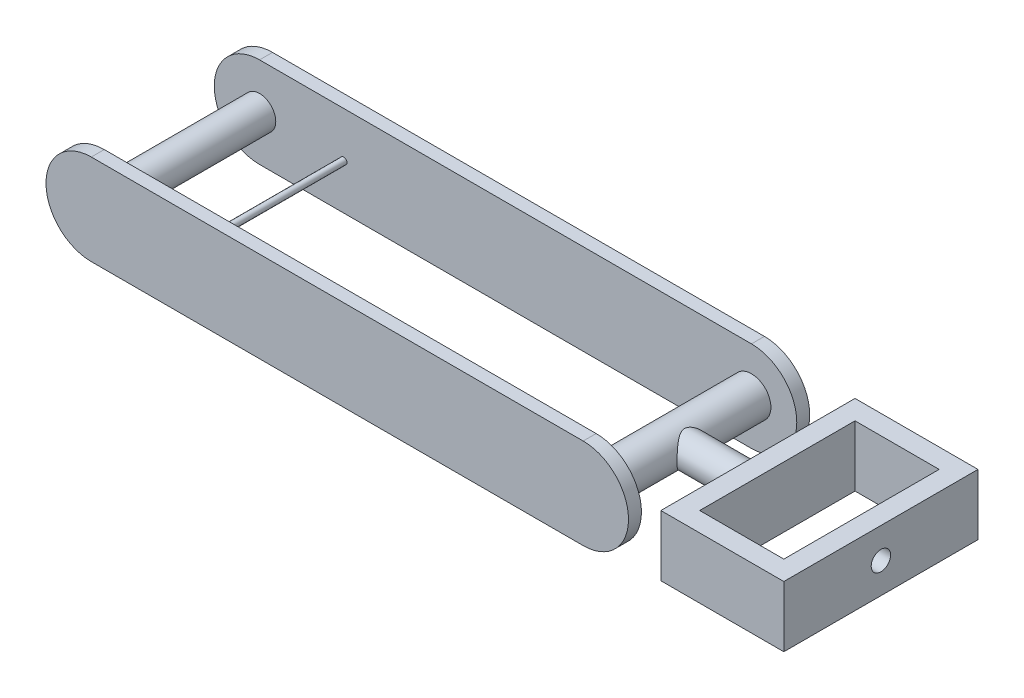
from build123d import *

# Parameters (mm, degrees)
BOSS_EXTRUDE1_DEPTH = 10
BOSS_EXTRUDE2_DEPTH = 10
SKETCH3_R           = 12.5
BOSS_EXTRUDE3_DEPTH = 145
SKETCH4_R           = 2.5
BOSS_EXTRUDE4_DEPTH = 145
SKETCH5_R           = 15
BOSS_EXTRUDE5_DEPTH = 145
SKETCH6_R           = 12.5
BOSS_EXTRUDE6_DEPTH = 65
SKETCH7_W           = 150
SKETCH7_H           = 47.005771534
BOSS_EXTRUDE7_DEPTH = 15
SKETCH9_W           = 15
SKETCH9_H           = 47.005771534
BOSS_EXTRUDE8_DEPTH = 65
SKETCH10_W          = 150
SKETCH10_H          = 47.005771534
BOSS_EXTRUDE9_DEPTH = 15
SKETCH11_R          = 7.5
CUT_EXTRUDE1_DEPTH  = 15


with BuildPart() as part:
    # Sketch1 → Boss-Extrude1 (new body)
    with BuildSketch(Plane.XY):
        with BuildLine():
            Line((-190, 35), (190, 35))
            ThreePointArc((190, 35), (225, 0), (190, -35))
            Line((190, -35), (-190, -35))
            ThreePointArc((-190, -35), (-225, 0), (-190, 35))
        make_face()
    extrude(amount=BOSS_EXTRUDE1_DEPTH)



with BuildPart() as body_2:
    # Sketch2 → Boss-Extrude2 (new body)
    with BuildSketch(Plane.XY.offset(-120)):
        with BuildLine():
            Line((-190, 35), (190, 35))
            ThreePointArc((190, 35), (225, 0), (190, -35))
            Line((190, -35), (-190, -35))
            ThreePointArc((-190, -35), (-225, 0), (-190, 35))
        make_face()
    extrude(amount=-BOSS_EXTRUDE2_DEPTH)


with BuildPart() as part_1:
    add(part.part)

    add(body_2.part)  # Boss-Extrude3 merges body 2
    # Sketch3 → Boss-Extrude3 (add)
    with BuildSketch(Plane.XY.offset(10)):
        with Locations((-190, 0)):
            Circle(SKETCH3_R)
    extrude(amount=-BOSS_EXTRUDE3_DEPTH)

    # Sketch4 → Boss-Extrude4 (add)
    with BuildSketch(Plane.XY.offset(10)):
        with Locations((-125, 0)):
            Circle(SKETCH4_R)
    extrude(amount=-BOSS_EXTRUDE4_DEPTH)

    # Sketch5 → Boss-Extrude5 (add)
    with BuildSketch(Plane.XY.offset(10)):
        with Locations((190, 0)):
            Circle(SKETCH5_R)
    extrude(amount=-BOSS_EXTRUDE5_DEPTH)

    # Sketch6 → Boss-Extrude6 (add)
    with BuildSketch(Plane(origin=(190, 0, 0), x_dir=(0, 0, -1), z_dir=(1, 0, 0))):
        with Locations((60, 0)):
            Circle(SKETCH6_R)
    extrude(amount=BOSS_EXTRUDE6_DEPTH)

    # Sketch7 → Boss-Extrude7 (add)
    with BuildSketch(Plane(origin=(255, 0, 0), x_dir=(0, 0, -1), z_dir=(1, 0, 0))):
        with Locations((60, 0)):
            Rectangle(SKETCH7_W, SKETCH7_H)
    extrude(amount=BOSS_EXTRUDE7_DEPTH)

    # Sketch9 → Boss-Extrude8 (add)
    with BuildSketch(Plane(origin=(270, 0, 0), x_dir=(0, 0, -1), z_dir=(1, 0, 0))):
        with Locations((-7.5, 0)):
            Rectangle(SKETCH9_W, SKETCH9_H)
        with Locations((127.5, 0)):
            Rectangle(SKETCH9_W, SKETCH9_H)
    extrude(amount=BOSS_EXTRUDE8_DEPTH)

    # Sketch10 → Boss-Extrude9 (add)
    with BuildSketch(Plane(origin=(335, 0, 0), x_dir=(0, 0, -1), z_dir=(1, 0, 0))):
        with Locations((60, 0)):
            Rectangle(SKETCH10_W, SKETCH10_H)
    extrude(amount=BOSS_EXTRUDE9_DEPTH)

    # Sketch11 → Cut-Extrude1 (cut)
    with BuildSketch(Plane(origin=(350, 0, 0), x_dir=(0, 0, -1), z_dir=(1, 0, 0))):
        with Locations((60, 0)):
            Circle(SKETCH11_R)
    extrude(amount=-CUT_EXTRUDE1_DEPTH, mode=Mode.SUBTRACT)


solid = part_1.part
